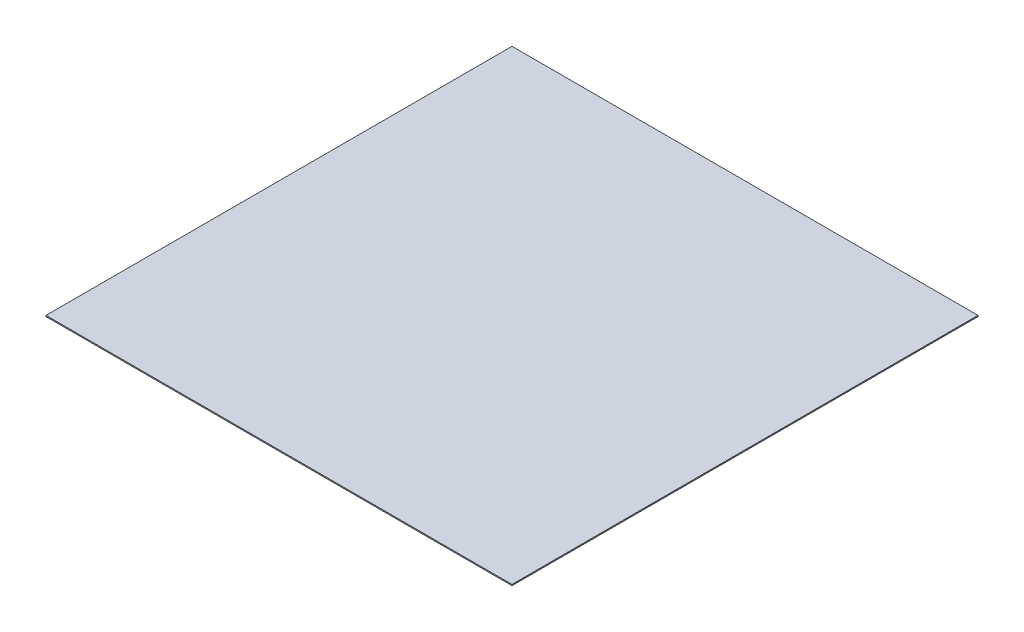
from build123d import *

# Parameters (mm, degrees)
SKETCH_1_W      = 210
SKETCH_1_H      = 210
EXTRUDE_1_DEPTH = 0.5


with BuildPart() as part:
    # 草图1 → 凸台-拉伸1 (new body)
    with BuildSketch(Plane(origin=(0, 0, 0), x_dir=(1, 0, 0), z_dir=(0, 1, 0))):
        with Locations((105, 105)):
            Rectangle(SKETCH_1_W, SKETCH_1_H)
    extrude(amount=EXTRUDE_1_DEPTH)


solid = part.part
